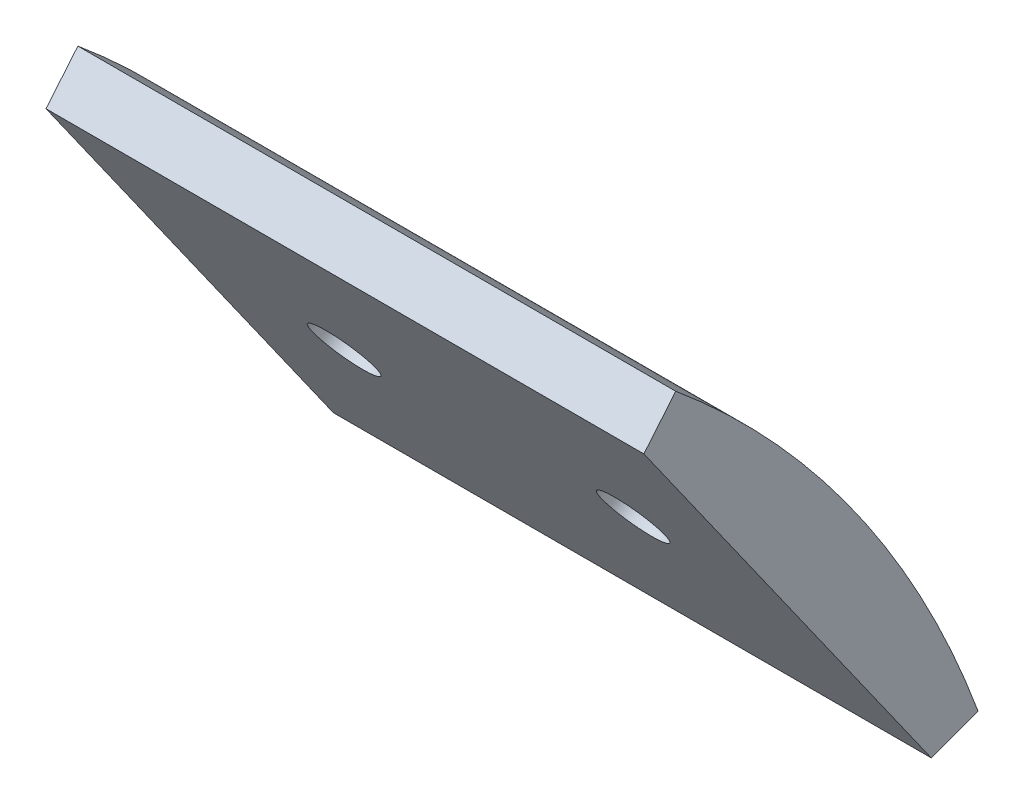
from build123d import *

# Parameters (mm, degrees)
BOSS_EXTRUDE1_DEPTH = 30
CUT_EXTRUDE1_REACH  = 16.804
SKETCH4_R           = 1.605


with BuildPart() as part:
    # Sketch3 → Boss-Extrude1 (new body)
    with BuildSketch(Plane(origin=(0, 0, 0), x_dir=(0, 0, -1), z_dir=(1, 0, 0))):
        with BuildLine():
            ThreePointArc((47.666821582, 17.564570029), (41.497171662, 29.302299296), (32.5, 39.043437349))
            Line((32.5, 39.043437349), (30.900590551, 37.122008345))
            ThreePointArc((30.900590551, 37.122008345), (39.454988017, 27.860257008), (45.321013433, 16.700171897))
            Line((45.321013433, 16.700171897), (47.666821582, 17.564570029))
        make_face()
        with BuildLine():
            ThreePointArc((30.900590551, 37.122008345), (39.454988017, 27.860257008), (45.321013433, 16.700171897))
            Line((45.321013433, 16.700171897), (30.900590551, 37.122008345))
        make_face()
    extrude(amount=BOSS_EXTRUDE1_DEPTH)

    # Sketch4 → Cut-Extrude1 (cut, up to next)
    with BuildSketch(Plane(origin=(0, 26.911090121, -38.110801992), x_dir=(1, 0, 0), z_dir=(0, -0.576816915, 0.816873458)), mode=Mode.PRIVATE) as cut_extrude1_sk1:
        with Locations((7.75, 0)):
            Circle(SKETCH4_R)
    cut_extrude1_tool1 = extrude(cut_extrude1_sk1.sketch, amount=-CUT_EXTRUDE1_REACH, mode=Mode.PRIVATE) & part.part
    add(cut_extrude1_tool1.solids().sort_by_distance((7.75, 26.91109, -38.110802))[0], mode=Mode.SUBTRACT)
    # Sketch4 → Cut-Extrude1 (cut, up to next)
    with BuildSketch(Plane(origin=(0, 26.911090121, -38.110801992), x_dir=(1, 0, 0), z_dir=(0, -0.576816915, 0.816873458)), mode=Mode.PRIVATE) as cut_extrude1_sk2:
        with Locations((22.25, 0)):
            Circle(SKETCH4_R)
    cut_extrude1_tool2 = extrude(cut_extrude1_sk2.sketch, amount=-CUT_EXTRUDE1_REACH, mode=Mode.PRIVATE) & part.part
    add(cut_extrude1_tool2.solids().sort_by_distance((22.25, 26.91109, -38.110802))[0], mode=Mode.SUBTRACT)


solid = part.part
